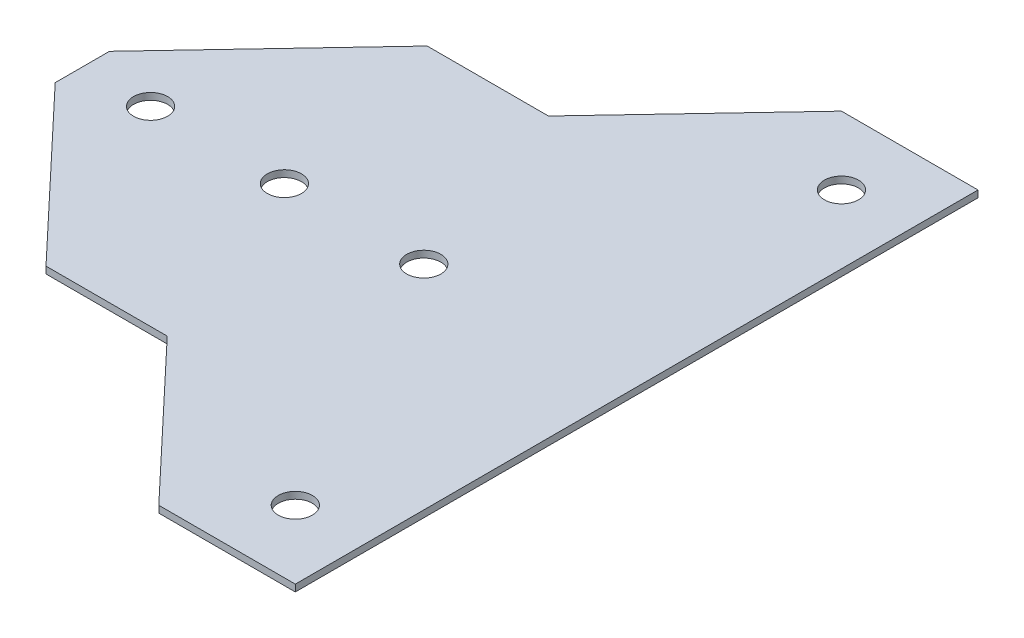
from build123d import *

# Parameters (mm, degrees)
SKETCH1_R           = 2.5
BOSS_EXTRUDE1_DEPTH = 1


with BuildPart() as part:
    # Sketch1 → Boss-Extrude1 (new body)
    with BuildSketch(Plane(origin=(0, 0, 0), x_dir=(1, 0, 0), z_dir=(0, 1, 0))):
        Polygon((20.6, 50), (40.6, 50), (40.6, -50), (20.6, -50), (-0.238673257, -27.92), (-18, -27.92), (-40.6, -3.973753814), (-40.6, 3.973753814), (-18, 27.92), (-0.238673257, 27.92), align=None)
        with Locations((-30.6, 0)):
            Circle(SKETCH1_R, mode=Mode.SUBTRACT)
        with Locations((30.6, 40)):
            Circle(SKETCH1_R, mode=Mode.SUBTRACT)
        with Locations((30.6, -40)):
            Circle(SKETCH1_R, mode=Mode.SUBTRACT)
        with Locations((9.42, 0)):
            Circle(SKETCH1_R, mode=Mode.SUBTRACT)
        with Locations((-11, 0)):
            Circle(SKETCH1_R, mode=Mode.SUBTRACT)
    extrude(amount=BOSS_EXTRUDE1_DEPTH)


solid = part.part
